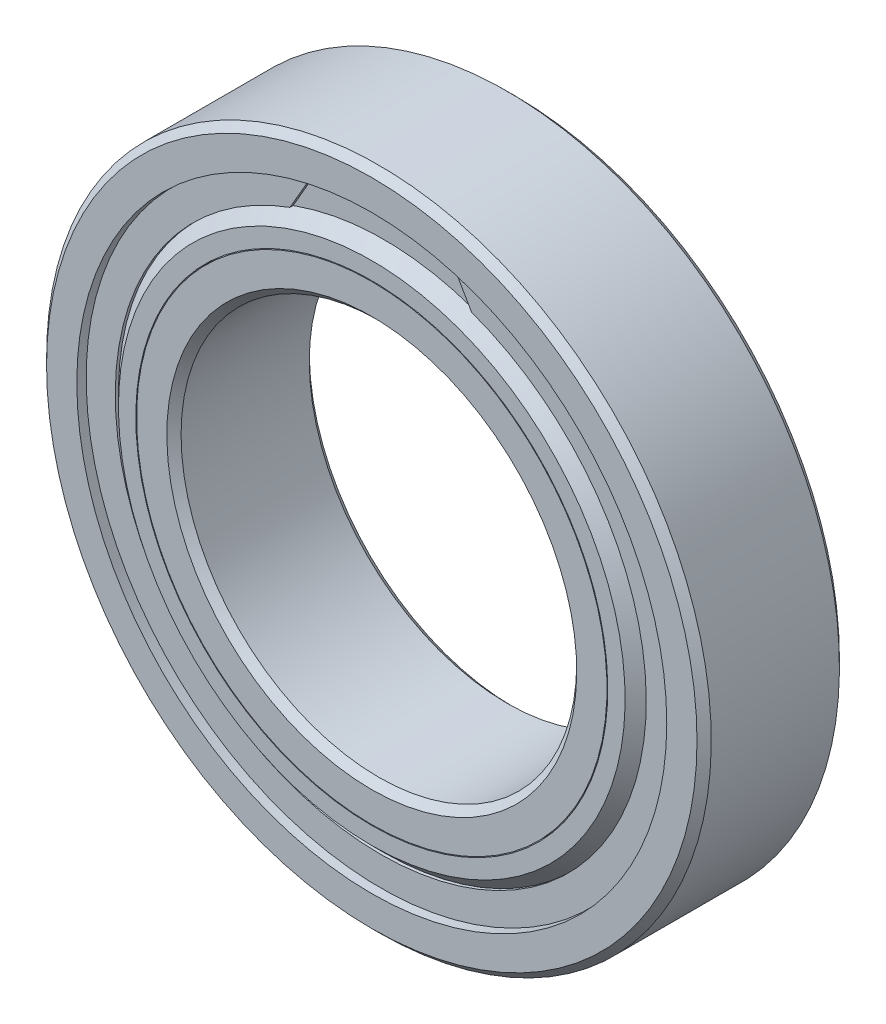
from build123d import *

# Parameters (mm, degrees)
SKETCH5_W           = 0.381
SKETCH5_H           = 1.838088889
BOSS_EXTRUDE1_DEPTH = 0.2
CIRPATTERN1_COUNT   = 15


with BuildPart() as part:
    # Sketch5 → Revolve1 (revolve)
    with BuildSketch(Plane(origin=(0, 0, 0), x_dir=(0, 0, -1), z_dir=(1, 0, 0))):
        with BuildLine():
            Line((4.05, 21), (-4.05, 21))
            Line((-4.05, 21), (-4.5, 20.55))
            Line((-4.5, 20.55), (-4.5, 18.638888889))
            Line((-4.5, 18.638888889), (-2, 18.638888889))
            ThreePointArc((-2, 18.638888889), (0, 19.500981867), (2, 18.638888889))
            Line((2, 18.638888889), (4.5, 18.638888889))
            Line((4.5, 18.638888889), (4.5, 20.55))
            Line((4.5, 20.55), (4.05, 21))
        make_face()
        with Locations((3.541890662, 17.694444445)):
            Rectangle(SKETCH5_W, SKETCH5_H)
        with Locations((-3.541890662, 17.694444445)):
            Rectangle(SKETCH5_W, SKETCH5_H)
    revolve(axis=Axis((0, 0, 4.5), (0, 0, -1)))


with BuildPart() as body_2:
    # Sketch3 → Revolve3 (revolve)
    with BuildSketch(Plane(origin=(0, 0, 0), x_dir=(0, 0, -1), z_dir=(1, 0, 0))):
        with BuildLine():
            Line((-4.5, 14.861111111), (-2, 14.861111111))
            ThreePointArc((-2, 14.861111111), (0, 13.999018133), (2, 14.861111111))
            Line((2, 14.861111111), (4.5, 14.861111111))
            Line((4.5, 14.861111111), (4.5, 12.95))
            Line((4.5, 12.95), (4.05, 12.5))
            Line((4.05, 12.5), (-4.05, 12.5))
            Line((-4.05, 12.5), (-4.5, 12.95))
            Line((-4.5, 12.95), (-4.5, 14.861111111))
        make_face()
    revolve(axis=Axis((0, 0, 4.5), (0, 0, -1)))


with BuildPart() as body_3:
    # Sketch9 → Revolve5 (revolve)
    with BuildSketch(Plane(origin=(0, 0, 0), x_dir=(0, 0, -1), z_dir=(1, 0, 0))):
        Polygon((-3.732390662, 16.7754), (-4.5, 16.007790662), (-4.5, 14.911111111), (-3.351390662, 14.911111111), (-3.351390662, 16.7754), align=None)
        Polygon((3.732390662, 16.7754), (3.351390662, 16.7754), (3.351390662, 14.911111111), (4.5, 14.911111111), (4.5, 16.007790662), align=None)
    revolve(axis=Axis((0, 0, 4.5), (0, 0, -1)))


with BuildPart() as body_4:
    # Sketch10 → Boss-Extrude1 (new body)
    with BuildSketch(Plane.XY.offset(3.732390662)):
        with BuildLine():
            Line((-5.737524712, 15.763719591), (-4.396252084, 18.086871931))
            ThreePointArc((-4.396252084, 18.086871931), (0, -18.613488889), (4.396252084, 18.086871931))
            Line((4.396252084, 18.086871931), (5.737524712, 15.763719591))
            ThreePointArc((5.737524712, 15.763719591), (0, -16.7754), (-5.737524712, 15.763719591))
        make_face()
    extrude(amount=BOSS_EXTRUDE1_DEPTH)


with BuildPart() as body_5:
    # Mirror2: mirrored copy
    add(body_4.part.mirror(Plane.XY))


with BuildPart() as body_6:
    # Sketch4 → Revolve4 (revolve)
    with BuildSketch(Plane(origin=(0, 0, 0), x_dir=(0, 0, -1), z_dir=(1, 0, 0))):
        with BuildLine():
            Line((-2.750981867, 16.75), (2.750981867, 16.75))
            ThreePointArc((2.750981867, 16.75), (0, 19.500981867), (-2.750981867, 16.75))
        make_face()
    revolve(axis=Axis((0, 16.75, 2.750981867), (0, 0, -1)))


with BuildPart() as cirpattern1_1:
    # CirPattern1: pattern copy
    add(body_6.part.rotate(Axis((0, 0, 0), (0, 0, 1)), 1 * 360 / CIRPATTERN1_COUNT))


with BuildPart() as cirpattern1_2:
    # CirPattern1: pattern copy
    add(body_6.part.rotate(Axis((0, 0, 0), (0, 0, 1)), 2 * 360 / CIRPATTERN1_COUNT))


with BuildPart() as cirpattern1_3:
    # CirPattern1: pattern copy
    add(body_6.part.rotate(Axis((0, 0, 0), (0, 0, 1)), 3 * 360 / CIRPATTERN1_COUNT))


with BuildPart() as cirpattern1_4:
    # CirPattern1: pattern copy
    add(body_6.part.rotate(Axis((0, 0, 0), (0, 0, 1)), 4 * 360 / CIRPATTERN1_COUNT))


with BuildPart() as cirpattern1_5:
    # CirPattern1: pattern copy
    add(body_6.part.rotate(Axis((0, 0, 0), (0, 0, 1)), 5 * 360 / CIRPATTERN1_COUNT))


with BuildPart() as cirpattern1_6:
    # CirPattern1: pattern copy
    add(body_6.part.rotate(Axis((0, 0, 0), (0, 0, 1)), 6 * 360 / CIRPATTERN1_COUNT))


with BuildPart() as cirpattern1_7:
    # CirPattern1: pattern copy
    add(body_6.part.rotate(Axis((0, 0, 0), (0, 0, 1)), 7 * 360 / CIRPATTERN1_COUNT))


with BuildPart() as cirpattern1_8:
    # CirPattern1: pattern copy
    add(body_6.part.rotate(Axis((0, 0, 0), (0, 0, 1)), 8 * 360 / CIRPATTERN1_COUNT))


with BuildPart() as cirpattern1_9:
    # CirPattern1: pattern copy
    add(body_6.part.rotate(Axis((0, 0, 0), (0, 0, 1)), 9 * 360 / CIRPATTERN1_COUNT))


with BuildPart() as cirpattern1_10:
    # CirPattern1: pattern copy
    add(body_6.part.rotate(Axis((0, 0, 0), (0, 0, 1)), 10 * 360 / CIRPATTERN1_COUNT))


with BuildPart() as cirpattern1_11:
    # CirPattern1: pattern copy
    add(body_6.part.rotate(Axis((0, 0, 0), (0, 0, 1)), 11 * 360 / CIRPATTERN1_COUNT))


with BuildPart() as cirpattern1_12:
    # CirPattern1: pattern copy
    add(body_6.part.rotate(Axis((0, 0, 0), (0, 0, 1)), 12 * 360 / CIRPATTERN1_COUNT))


with BuildPart() as cirpattern1_13:
    # CirPattern1: pattern copy
    add(body_6.part.rotate(Axis((0, 0, 0), (0, 0, 1)), 13 * 360 / CIRPATTERN1_COUNT))


with BuildPart() as cirpattern1_14:
    # CirPattern1: pattern copy
    add(body_6.part.rotate(Axis((0, 0, 0), (0, 0, 1)), 14 * 360 / CIRPATTERN1_COUNT))


solid = Compound([part.part, body_2.part, body_3.part, body_4.part, body_5.part, body_6.part, cirpattern1_1.part, cirpattern1_2.part, cirpattern1_3.part, cirpattern1_4.part, cirpattern1_5.part, cirpattern1_6.part, cirpattern1_7.part, cirpattern1_8.part, cirpattern1_9.part, cirpattern1_10.part, cirpattern1_11.part, cirpattern1_12.part, cirpattern1_13.part, cirpattern1_14.part])
